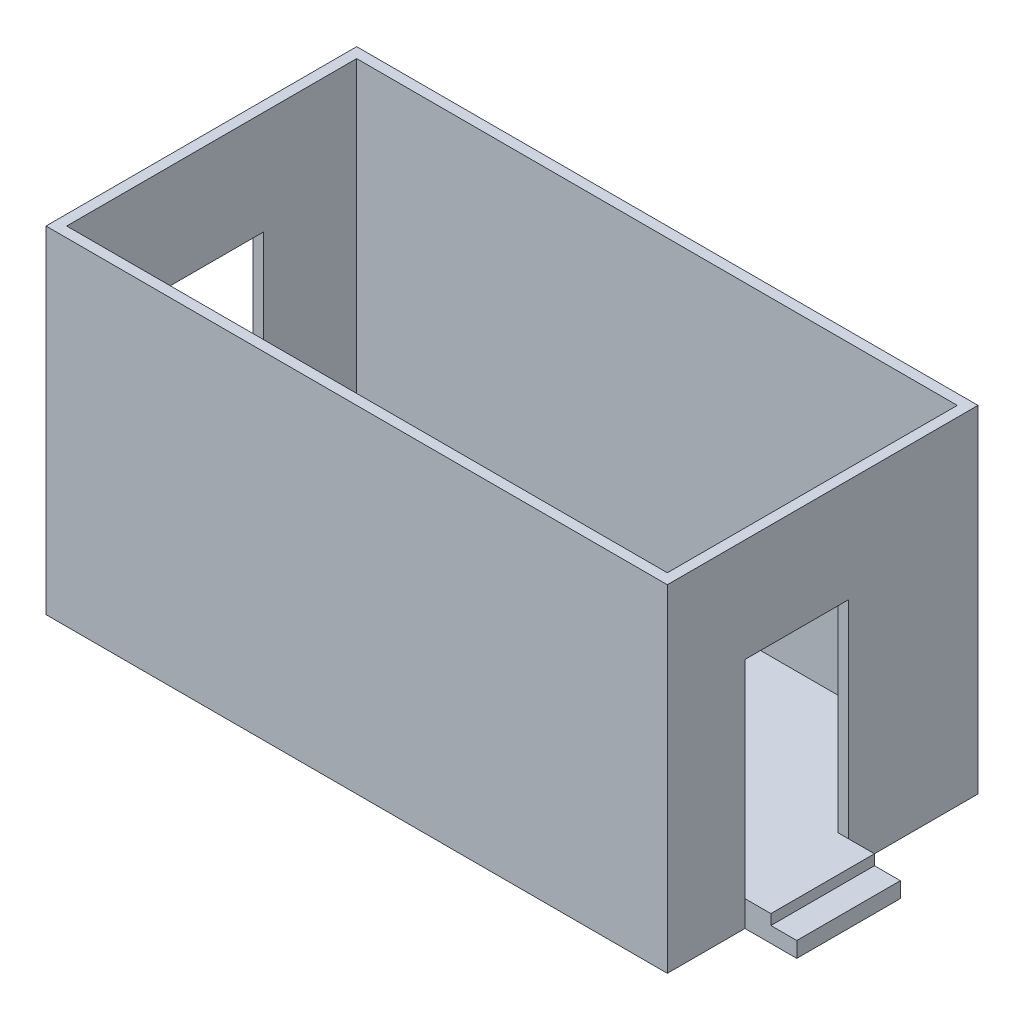
from build123d import *

# Parameters (mm, degrees)
SKETCH1_W           = 6000
SKETCH1_H           = 3000
BOSS_EXTRUDE1_DEPTH = 250
SKETCH2_W           = 6000
SKETCH2_H           = 3000
SKETCH2_W_2         = 5800
SKETCH2_H_2         = 2800
BOSS_EXTRUDE2_DEPTH = 3000
SKETCH3_W           = 1000
SKETCH3_H           = 2000
CUT_EXTRUDE1_DEPTH  = 250
SKETCH4_W           = 1000
SKETCH4_H           = 2000
CUT_EXTRUDE2_DEPTH  = 250
SKETCH6_W           = 1000
SKETCH6_H           = 250
BOSS_EXTRUDE4_DEPTH = 500
SKETCH7_W           = 1000
SKETCH7_H           = 250
BOSS_EXTRUDE5_DEPTH = 500
SKETCH8_W           = 250
SKETCH8_H           = 1000
CUT_EXTRUDE4_DEPTH  = 100
SKETCH9_W           = 250
SKETCH9_H           = 1000
CUT_EXTRUDE5_DEPTH  = 100


with BuildPart() as part:
    # Sketch1 → Boss-Extrude1 (new body)
    with BuildSketch(Plane(origin=(0, 0, 0), x_dir=(1, 0, 0), z_dir=(0, 1, 0))):
        Rectangle(SKETCH1_W, SKETCH1_H)
    extrude(amount=BOSS_EXTRUDE1_DEPTH)

    # Sketch2 → Boss-Extrude2 (add)
    with BuildSketch(Plane(origin=(0, 250, 0), x_dir=(1, 0, 0), z_dir=(0, 1, 0))):
        Rectangle(SKETCH2_W, SKETCH2_H)
        Rectangle(SKETCH2_W_2, SKETCH2_H_2, mode=Mode.SUBTRACT)
    extrude(amount=BOSS_EXTRUDE2_DEPTH)

    # Sketch3 → Cut-Extrude1 (cut)
    with BuildSketch(Plane.ZY.offset(3000)):
        with Locations((0, 1250)):
            Rectangle(SKETCH3_W, SKETCH3_H)
    extrude(amount=-CUT_EXTRUDE1_DEPTH, mode=Mode.SUBTRACT)

    # Sketch4 → Cut-Extrude2 (cut)
    with BuildSketch(Plane(origin=(3000, 0, 0), x_dir=(0, 0, -1), z_dir=(1, 0, 0))):
        with Locations((-250, 1250)):
            Rectangle(SKETCH4_W, SKETCH4_H)
    extrude(amount=-CUT_EXTRUDE2_DEPTH, mode=Mode.SUBTRACT)

    # Sketch6 → Boss-Extrude4 (add)
    with BuildSketch(Plane(origin=(3000, 0, 0), x_dir=(0, 0, -1), z_dir=(1, 0, 0))):
        with Locations((-250, 125)):
            Rectangle(SKETCH6_W, SKETCH6_H)
    extrude(amount=BOSS_EXTRUDE4_DEPTH)

    # Sketch7 → Boss-Extrude5 (add)
    with BuildSketch(Plane.ZY.offset(3000)):
        with Locations((0, 125)):
            Rectangle(SKETCH7_W, SKETCH7_H)
    extrude(amount=BOSS_EXTRUDE5_DEPTH)

    # Sketch8 → Cut-Extrude4 (cut)
    with BuildSketch(Plane(origin=(0, 250, 0), x_dir=(1, 0, 0), z_dir=(0, 1, 0))):
        with Locations((3375, -250)):
            Rectangle(SKETCH8_W, SKETCH8_H)
    extrude(amount=-CUT_EXTRUDE4_DEPTH, mode=Mode.SUBTRACT)

    # Sketch9 → Cut-Extrude5 (cut)
    with BuildSketch(Plane(origin=(0, 250, 0), x_dir=(1, 0, 0), z_dir=(0, 1, 0))):
        with Locations((-3375, 0)):
            Rectangle(SKETCH9_W, SKETCH9_H)
    extrude(amount=-CUT_EXTRUDE5_DEPTH, mode=Mode.SUBTRACT)


solid = part.part
